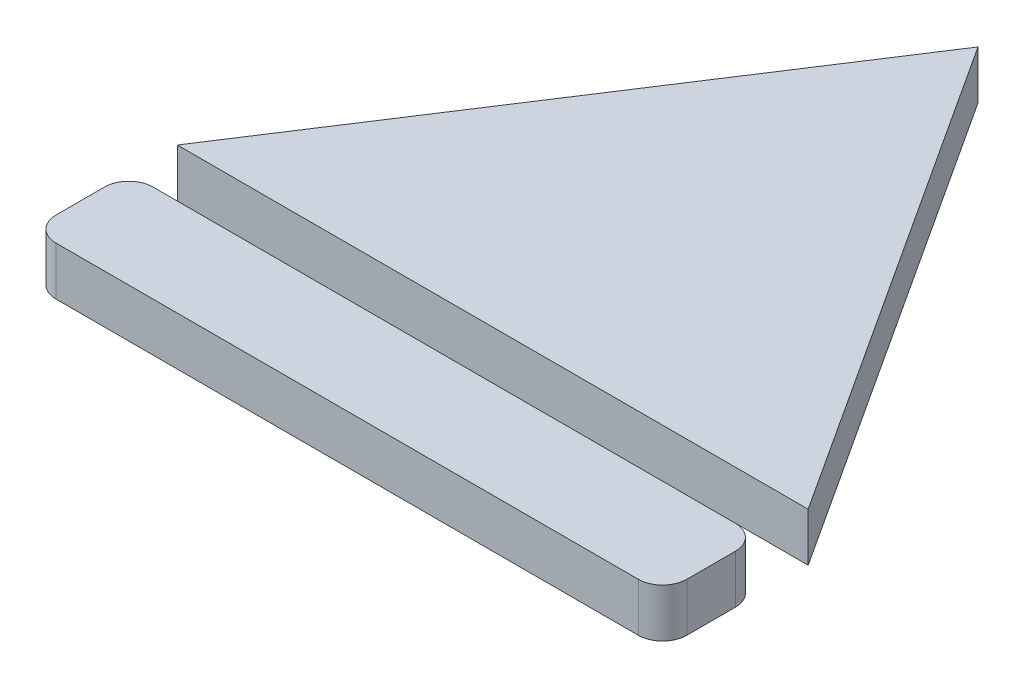
from build123d import *

# Parameters (mm, degrees)
BOSS_EXTRUDE1_DEPTH   = 1
BOSS_EXTRUDE1_2_DEPTH = 1


with BuildPart() as part:
    # Sketch2 → Boss-Extrude1 (new body)
    with BuildSketch(Plane(origin=(0, 0, 0), x_dir=(1, 0, 0), z_dir=(0, 1, 0))):
        Polygon((0, 0), (13, 0), (6.5, 10), align=None)
    extrude(amount=BOSS_EXTRUDE1_DEPTH)


with BuildPart() as body_2:
    # Sketch2 → Boss-Extrude1 2 (new body)
    with BuildSketch(Plane(origin=(0, 0, 0), x_dir=(1, 0, 0), z_dir=(0, 1, 0))):
        with BuildLine():
            Line((0.5, -1), (12.5, -1))
            ThreePointArc((12.5, -1), (12.853553391, -1.146446609), (13, -1.5))
            Line((13, -1.5), (13, -2.5))
            ThreePointArc((13, -2.5), (12.853553391, -2.853553391), (12.5, -3))
            Line((12.5, -3), (0.5, -3))
            ThreePointArc((0.5, -3), (0.146446609, -2.853553391), (0, -2.5))
            Line((0, -2.5), (0, -1.5))
            ThreePointArc((0, -1.5), (0.146446609, -1.146446609), (0.5, -1))
        make_face()
    extrude(amount=BOSS_EXTRUDE1_2_DEPTH)


solid = Compound([part.part, body_2.part])
